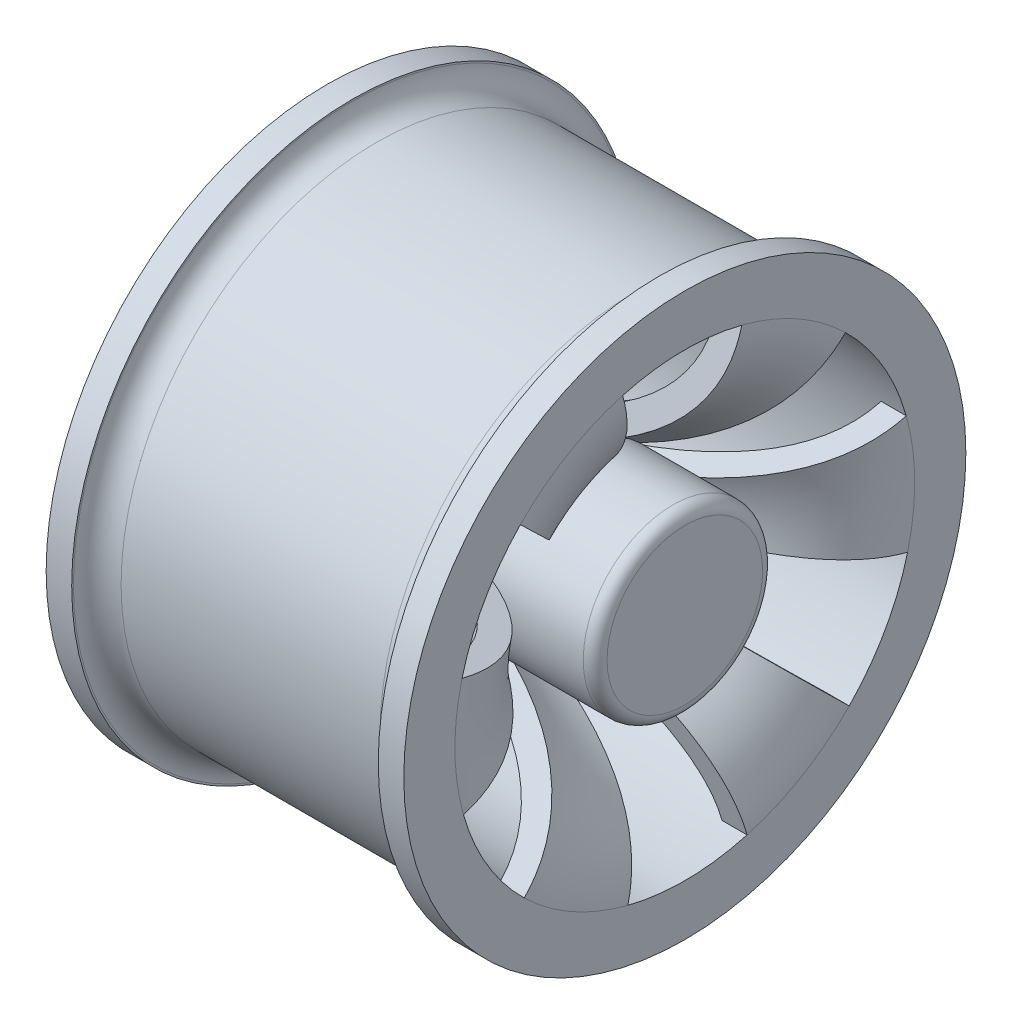
from build123d import *

# Parameters (mm, degrees)
SKETCH3_R           = 19.108098946
SKETCH3_R_2         = 13.589
BOSS_EXTRUDE1_DEPTH = 76.2
SKETCH4_R           = 19.108098946
BOSS_EXTRUDE2_DEPTH = 12.7
CUT_EXTRUDE1_DEPTH  = 114.910644964
CIRPATTERN5_COUNT   = 6
FILLET3_R           = 2.54


with BuildPart() as part:
    # Sketch2 → Revolve6 (revolve)
    with BuildSketch(Plane.XY, mode=Mode.PRIVATE) as revolve6_sk:
        with BuildLine():
            Line((-38.1, 48.9858304), (32.766, 48.9858304))
            add(Edge.make_bspline(
                [(32.766, 48.9858304), (32.766, 48.473213883), (32.730477643, 47.434465755), (32.525585413, 45.472194188), (32.032134598, 43.139455735), (31.089586373, 40.514019315), (29.388655066, 37.194741731), (26.460294002, 33.345321166), (21.833242504, 29.216662773), (16.378093486, 25.651607689), (11.428357271, 23.188179655), (7.408898616, 21.530115882), (4.409581475, 20.442304822), (1.965899833, 19.66591321), (0.512509634, 19.249569139), (0.022549023, 19.11430692), (0, 19.108098946)],
                knots=[0, 0, 0, 0, 0.03125, 0.0625, 0.125, 0.1875, 0.25, 0.375, 0.5, 0.625, 0.75, 0.8125, 0.875, 0.9375, 0.96875, 0.970258809, 0.970258809, 0.970258809, 0.970258809], degree=3))
            Line((0, 19.108098946), (0, 13.589))
            add(Edge.make_bspline(
                [(38.1, 48.9858304), (38.1, 28.387632385), (15.682353172, 17.607604937), (0, 13.589)],
                knots=[0, 0, 0, 0, 1, 1, 1, 1], degree=3))
            Line((38.1, 48.9858304), (38.1, 59.8715084))
            Line((38.1, 59.8715084), (32.6571356, 59.8715084))
            Line((32.6571356, 59.8715084), (32.6571356, 59.508644))
            ThreePointArc((32.6571356, 59.508644), (31.169238048, 55.916541552), (27.5771356, 54.428644))
            Line((27.5771356, 54.428644), (-27.5771356, 54.428644))
            ThreePointArc((-27.5771356, 54.428644), (-31.169238048, 55.916541552), (-32.6571356, 59.508644))
            Line((-32.6571356, 59.508644), (-32.6571356, 59.8715084))
            Line((-32.6571356, 59.8715084), (-38.1, 59.8715084))
            Line((-38.1, 59.8715084), (-38.1, 48.9858304))
        make_face()
    revolve(revolve6_sk.sketch.rotate(Axis((0, 0, 0), (1, 0, 0)), 90), axis=Axis((0, 0, 0), (1, 0, 0)))

    # Sketch5 → Cut-Extrude1 (cut, through all)
    with BuildSketch(Plane(origin=(38.1, 0, 0), x_dir=(0, 0, -1), z_dir=(1, 0, 0))):
        with BuildLine():
            Line((-13.259549195, 47.157140871), (-5.17220543, 18.394774701))
            ThreePointArc((-5.17220543, 18.394774701), (-0.225993894, 19.10676247), (4.735674242, 18.511964639))
            Line((4.735674242, 18.511964639), (12.140450805, 47.457570884))
            ThreePointArc((12.140450805, 47.457570884), (-0.579361588, 48.982404189), (-13.259549195, 47.157140871))
        make_face()
    cut_extrude1 = extrude(amount=-CUT_EXTRUDE1_DEPTH, mode=Mode.SUBTRACT)

    # CirPattern5: Cut-Extrude1 ×6 about axis
    cirpattern5_axis = Axis((0, 0, 0), (1, 0, 0))
    for i in range(1, CIRPATTERN5_COUNT):
        add(cut_extrude1.rotate(cirpattern5_axis, i * 360 / CIRPATTERN5_COUNT), mode=Mode.SUBTRACT)


with BuildPart() as body_2:
    # Sketch3 → Boss-Extrude1 (new body)
    with BuildSketch(Plane.ZY.offset(38.1)):
        Circle(SKETCH3_R)
        Circle(SKETCH3_R_2, mode=Mode.SUBTRACT)
    extrude(amount=-BOSS_EXTRUDE1_DEPTH)

    # Sketch4 → Boss-Extrude2 (add)
    with BuildSketch(Plane(origin=(38.1, 0, 0), x_dir=(0, 0, -1), z_dir=(1, 0, 0))):
        with Locations(Location((0, 0, 0), (0, 0, 180))):
            Circle(SKETCH4_R)
    extrude(amount=-BOSS_EXTRUDE2_DEPTH)

    # Fillet3
    fillet3_edges = [body_2.edges().sort_by_distance(p)[0] for p in [
        (38.1, 0, -19.108098946),
    ]]
    fillet(fillet3_edges, radius=FILLET3_R)


solid = Compound([part.part, body_2.part])
